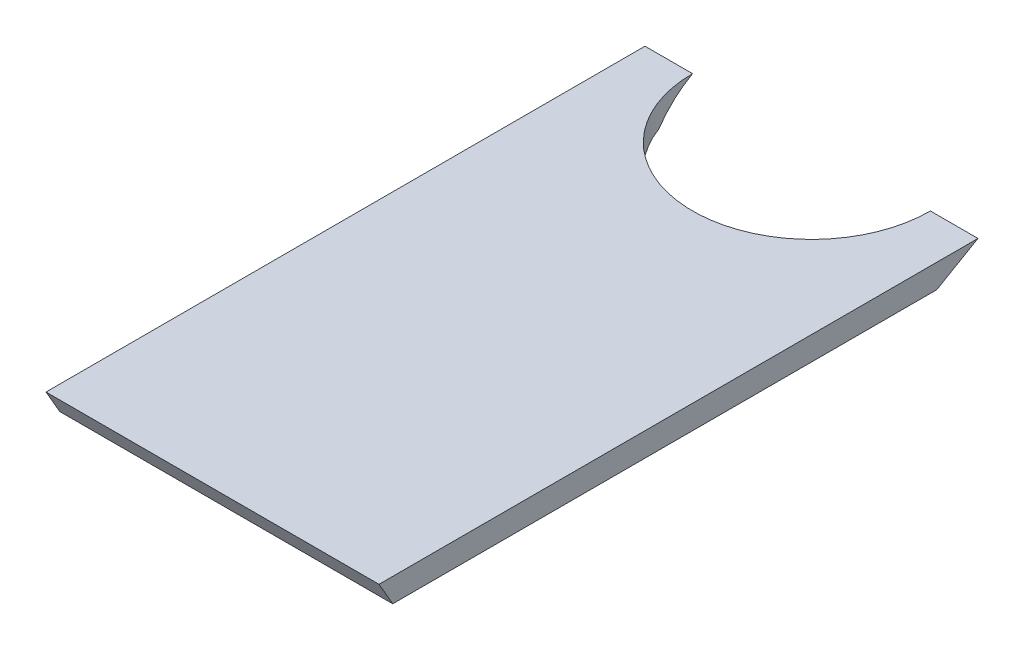
from build123d import *

# Parameters (mm, degrees)
BOSS_EXTRUDE1_DEPTH = 44.45
CUT_EXTRUDE1_DEPTH  = 7.35


with BuildPart() as part:
    # Sketch3 → Boss-Extrude1 (new body, symmetric)
    with BuildSketch(Plane(origin=(0, 0, 0), x_dir=(0, 0, -1), z_dir=(1, 0, 0))):
        Polygon((-88.825470595, 3.175), (-85.159296386, -3.175), (60.083377372, -3.175), (71.0819, 3.175), align=None)
    extrude(amount=BOSS_EXTRUDE1_DEPTH, both=True)

    # Sketch5 → Cut-Extrude1 (cut, through all)
    with BuildSketch(Plane(origin=(0, 3.175, 0), x_dir=(1, 0, 0), z_dir=(0, 1, 0))):
        with BuildLine():
            ThreePointArc((-31.75, 71.0819), (0, 39.3319), (31.75, 71.0819))
            Line((31.75, 71.0819), (-31.75, 71.0819))
        make_face()
    extrude(amount=-CUT_EXTRUDE1_DEPTH, mode=Mode.SUBTRACT)


solid = part.part
